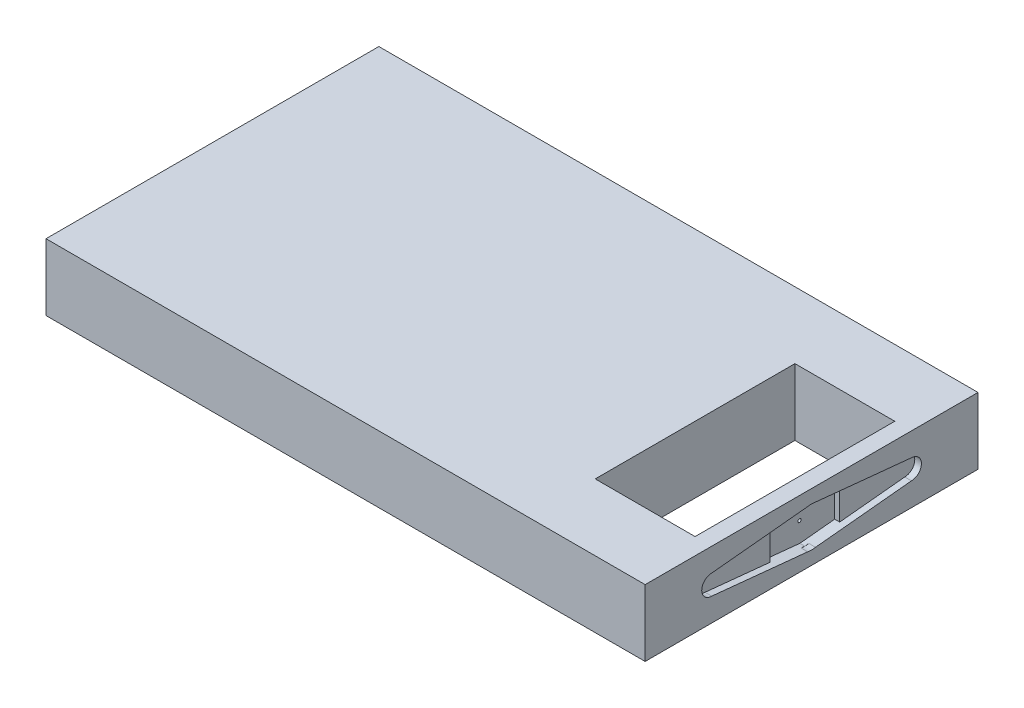
from build123d import *

# Parameters (mm, degrees)
SKETCH_1_W          = 180
SKETCH_1_H          = 100
EXTRUDE_2_DEPTH     = 20
CUT_EXTRUDE_3_DEPTH = 2
CUT_EXTRUDE_4_DEPTH = 3.5
SKETCH_6_W          = 30
SKETCH_6_H          = 60
CUT_EXTRUDE_5_DEPTH = 50
MM_1_D              = 1
MM_1_DEPTH          = 4
MM_1_TIP            = 0.30043031


with BuildPart() as part:
    # 草图1 → 凸台-拉伸2 (new body)
    with BuildSketch(Plane(origin=(0, 0, 0), x_dir=(1, 0, 0), z_dir=(0, 1, 0))):
        with Locations((90, 50)):
            Rectangle(SKETCH_1_W, SKETCH_1_H)
    extrude(amount=EXTRUDE_2_DEPTH)

    # 草图4 → 切除-拉伸3 (cut)
    with BuildSketch(Plane(origin=(180, 0, 0), x_dir=(0, 0, -1), z_dir=(1, 0, 0))):
        with BuildLine():
            Line((48.811881188, 15.881188119), (20, 13))
            ThreePointArc((20, 13), (17, 10), (20, 7))
            Line((20, 7), (48.811881188, 4.118811881))
            ThreePointArc((48.811881188, 4.118811881), (50, 4), (51.188118812, 4.118811881))
            Line((51.188118812, 4.118811881), (80, 7))
            ThreePointArc((80, 7), (83, 10), (80, 13))
            Line((80, 13), (51.188118812, 15.881188119))
            ThreePointArc((51.188118812, 15.881188119), (50, 16), (48.811881188, 15.881188119))
        make_face()
    extrude(amount=-CUT_EXTRUDE_3_DEPTH, mode=Mode.SUBTRACT)

    # 草图5 → 切除-拉伸4 (cut)
    with BuildSketch(Plane(origin=(180, 0, 0), x_dir=(0, 0, -1), z_dir=(1, 0, 0))):
        Polygon((50, 16), (39.552109503, 14.95521095), (39.552109503, 5.04478905), (50, 4), (60.447890497, 5.04478905), (60.447890497, 14.95521095), align=None)
    extrude(amount=-CUT_EXTRUDE_4_DEPTH, mode=Mode.SUBTRACT)

    # 草图6 → 切除-拉伸5 (cut)
    with BuildSketch(Plane(origin=(0, 20, 0), x_dir=(1, 0, 0), z_dir=(0, 1, 0))):
        with Locations((160, 50)):
            Rectangle(SKETCH_6_W, SKETCH_6_H)
    extrude(amount=-CUT_EXTRUDE_5_DEPTH, mode=Mode.SUBTRACT)

    # 大小mm 暗销孔1
    with Locations(Plane(origin=(176.5, 9.952512246, -49.877349569), x_dir=(0, 0, 1), z_dir=(1, 0, 0))):
        with Locations((0, 0)):
            Hole(MM_1_D / 2, depth=MM_1_DEPTH)
            with Locations((0, 0, -(MM_1_DEPTH + MM_1_TIP / 2))):  # 118° drill point
                Cone(0, MM_1_D / 2, MM_1_TIP, mode=Mode.SUBTRACT)


solid = part.part
